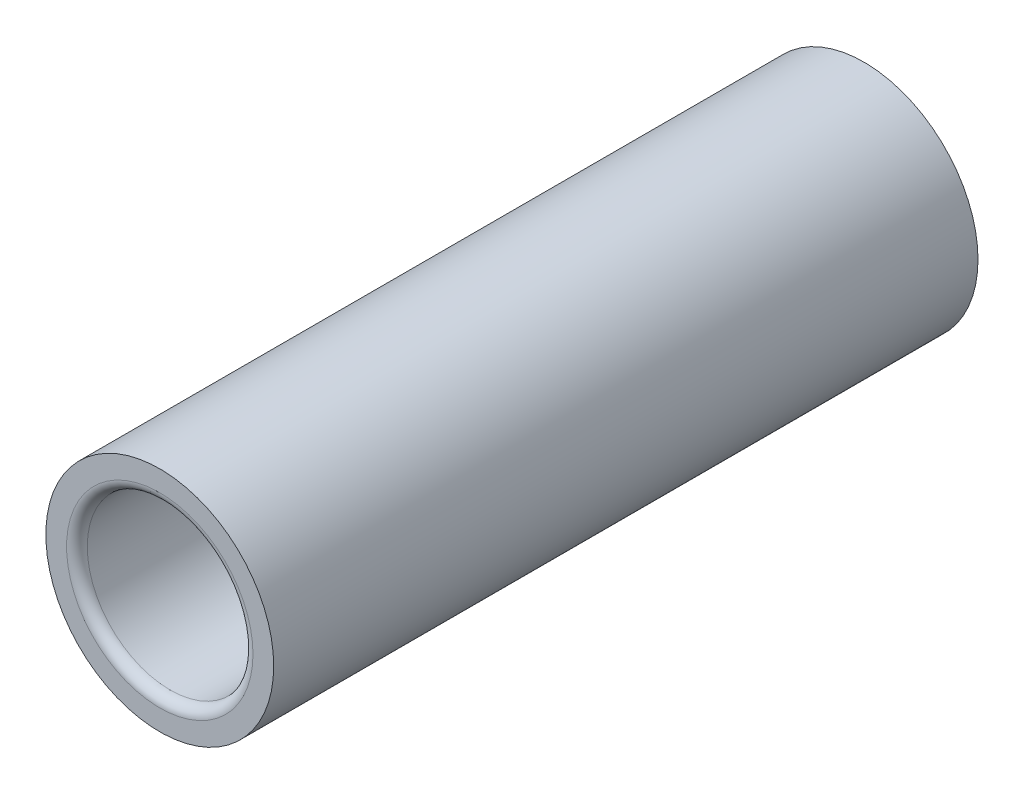
from build123d import *

# Parameters (mm, degrees)
SKETCH1_R           = 11
SKETCH1_R_2         = 8
BOSS_EXTRUDE1_DEPTH = 34
FILLET1_R           = 1


with BuildPart() as part:
    # Sketch1 → Boss-Extrude1 (new body, symmetric)
    with BuildSketch(Plane.XY):
        Circle(SKETCH1_R)
        Circle(SKETCH1_R_2, mode=Mode.SUBTRACT)
    extrude(amount=BOSS_EXTRUDE1_DEPTH, both=True)

    # Fillet1
    fillet1_edges = [part.edges().sort_by_distance(p)[0] for p in [
        (-8, 0, -34),
        (-8, 0, 34),
    ]]
    fillet(fillet1_edges, radius=FILLET1_R)


solid = part.part
